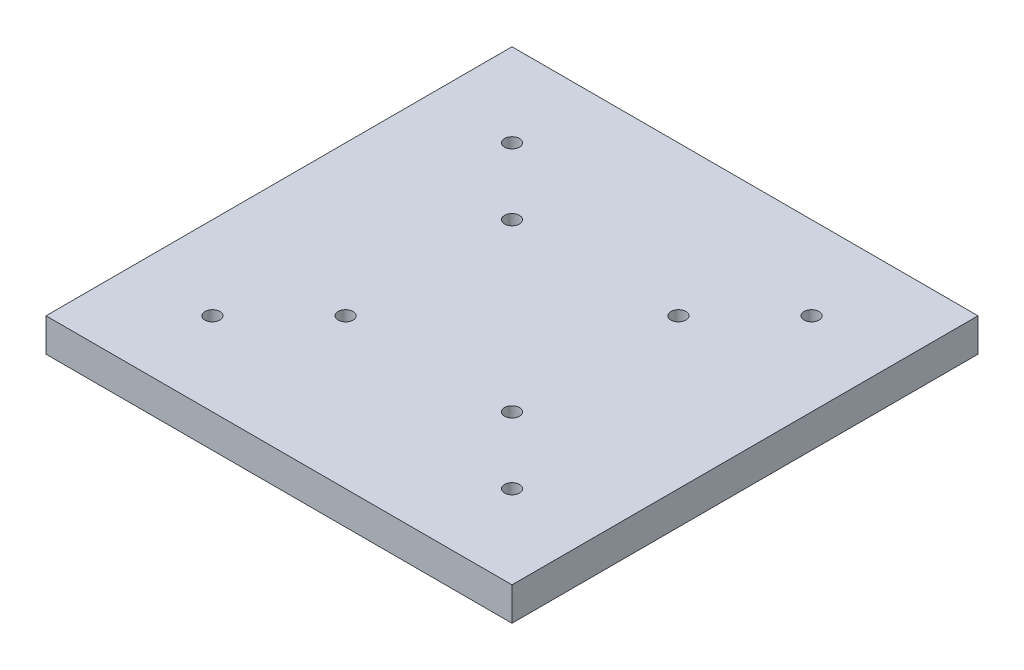
from build123d import *

# Parameters (mm, degrees)
SKETCH1_W            = 140
SKETCH1_H            = 140
BOSS_EXTRUDE1_DEPTH  = 10
M4_CLEARANCE_HOLE1_D = 4.5


with BuildPart() as part:
    # Sketch1 → Boss-Extrude1 (new body)
    with BuildSketch(Plane(origin=(0, 0, 0), x_dir=(1, 0, 0), z_dir=(0, 1, 0))):
        Rectangle(SKETCH1_W, SKETCH1_H)
    extrude(amount=-BOSS_EXTRUDE1_DEPTH)

    # M4 Clearance Hole1 (through all)
    with Locations(Plane(origin=(0, 0, 0), x_dir=(1, 0, 0), z_dir=(0, 1, 0))):
        with Locations((-45, 45), (-45, -45), (45, -45), (45, 45), (25, 25), (-25, 25), (-25, -25), (25, -25)):
            Hole(M4_CLEARANCE_HOLE1_D / 2)


solid = part.part
